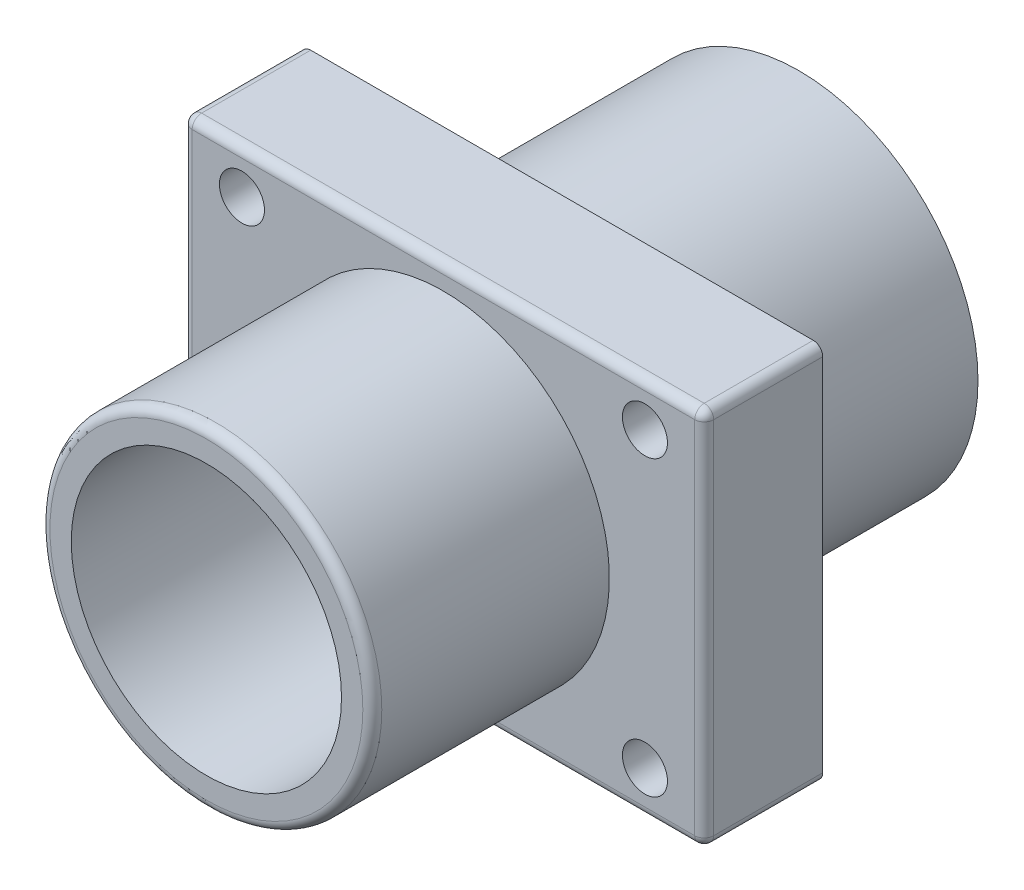
from build123d import *

# Parameters (mm, degrees)
SKETCH1_W            = 110
SKETCH1_H            = 80
BOSS_EXTRUDE1_DEPTH  = 25
SKETCH2_R            = 4.75
CUT_EXTRUDE1_DEPTH   = 25
LPATTERN1_COUNT      = 2
LPATTERN1_PITCH      = 85
LPATTERN1_COUNT_DIR2 = 2
LPATTERN1_PITCH_DIR2 = 61.8
SKETCH3_R            = 35
BOSS_EXTRUDE2_DEPTH  = 50
SKETCH4_R            = 37.75
BOSS_EXTRUDE3_DEPTH  = 50
SKETCH5_R            = 28.5
CUT_EXTRUDE2_DEPTH   = 75
SKETCH6_R            = 23
CUT_EXTRUDE3_DEPTH   = 50
FILLET1_R            = 2


with BuildPart() as part:
    # Sketch1 → Boss-Extrude1 (new body)
    with BuildSketch(Plane.XY):
        Rectangle(SKETCH1_W, SKETCH1_H)
    extrude(amount=BOSS_EXTRUDE1_DEPTH)

    # Sketch2 → Cut-Extrude1 (cut)
    with BuildSketch(Plane.XY.offset(25)):
        with Locations((-42.5, -30.9)):
            Circle(SKETCH2_R)
    cut_extrude1 = extrude(amount=-CUT_EXTRUDE1_DEPTH, mode=Mode.SUBTRACT)

    # LPattern1: Cut-Extrude1 2 × 2
    with Locations(*[(i * LPATTERN1_PITCH, j * LPATTERN1_PITCH_DIR2, 0) for i in range(LPATTERN1_COUNT) for j in range(LPATTERN1_COUNT_DIR2) if (i, j) != (0, 0)]):
        add(cut_extrude1, mode=Mode.SUBTRACT)

    # Sketch3 → Boss-Extrude2 (add)
    with BuildSketch(Plane.XY.offset(25)):
        Circle(SKETCH3_R)
    extrude(amount=BOSS_EXTRUDE2_DEPTH)

    # Sketch4 → Boss-Extrude3 (add)
    with BuildSketch(Plane(origin=(0, 0, 0), x_dir=(-1, 0, 0), z_dir=(0, 0, -1))):
        Circle(SKETCH4_R)
    extrude(amount=BOSS_EXTRUDE3_DEPTH)

    # Sketch5 → Cut-Extrude2 (cut)
    with BuildSketch(Plane.XY.offset(75)):
        Circle(SKETCH5_R)
    extrude(amount=-CUT_EXTRUDE2_DEPTH, mode=Mode.SUBTRACT)

    # Sketch6 → Cut-Extrude3 (cut)
    with BuildSketch(Plane.XY):
        Circle(SKETCH6_R)
    extrude(amount=-CUT_EXTRUDE3_DEPTH, mode=Mode.SUBTRACT)

    # Fillet1
    fillet1_edges = [part.edges().sort_by_distance(p)[0] for p in [
        (-55, 0, 25),
        (0, -40, 25),
        (-35, 0, 75),
        (55, 0, 25),
        (55, -40, 12.5),
        (-55, -40, 12.5),
        (-55, 40, 12.5),
        (55, 40, 12.5),
        (0, 40, 25),
    ]]
    fillet(fillet1_edges, radius=FILLET1_R)


solid = part.part
